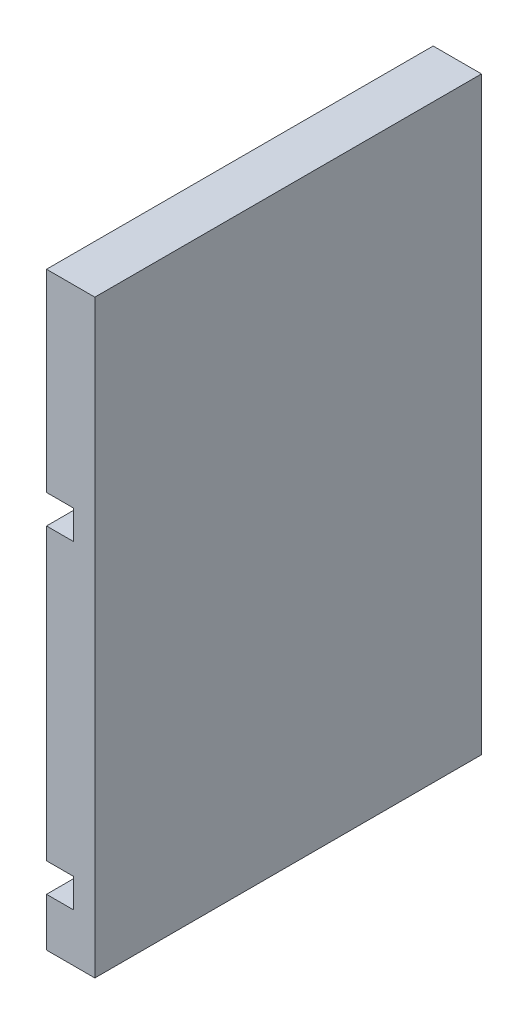
from build123d import *

# Parameters (mm, degrees)
BOSS_EXTRU_1_DEPTH = 40


with BuildPart() as part:
    # Esquisse1 → Boss.-Extru.1 (new body)
    with BuildSketch(Plane.XY):
        Polygon((0, 53), (5, 53), (5, -8), (0, -8), (0, -3), (2.787641371, -3), (2.787641371, 0), (0, 0), (0, 30), (2.787641371, 30), (2.787641371, 33), (0, 33), align=None)
    extrude(amount=BOSS_EXTRU_1_DEPTH)


solid = part.part
